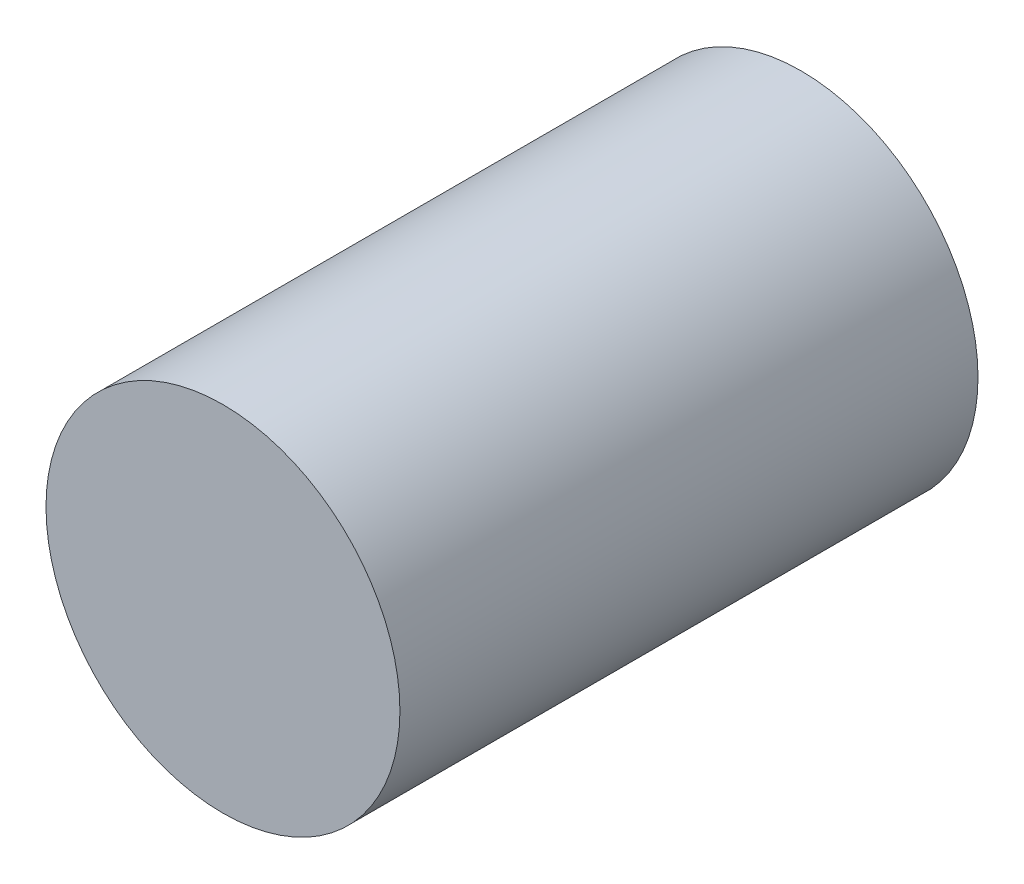
from build123d import *

# Parameters (mm, degrees)
SKETCH1_R           = 3
BOSS_EXTRUDE1_DEPTH = 9.8


with BuildPart() as part:
    # Sketch1 → Boss-Extrude1 (new body)
    with BuildSketch(Plane.XY):
        Circle(SKETCH1_R)
    extrude(amount=BOSS_EXTRUDE1_DEPTH)


solid = part.part
